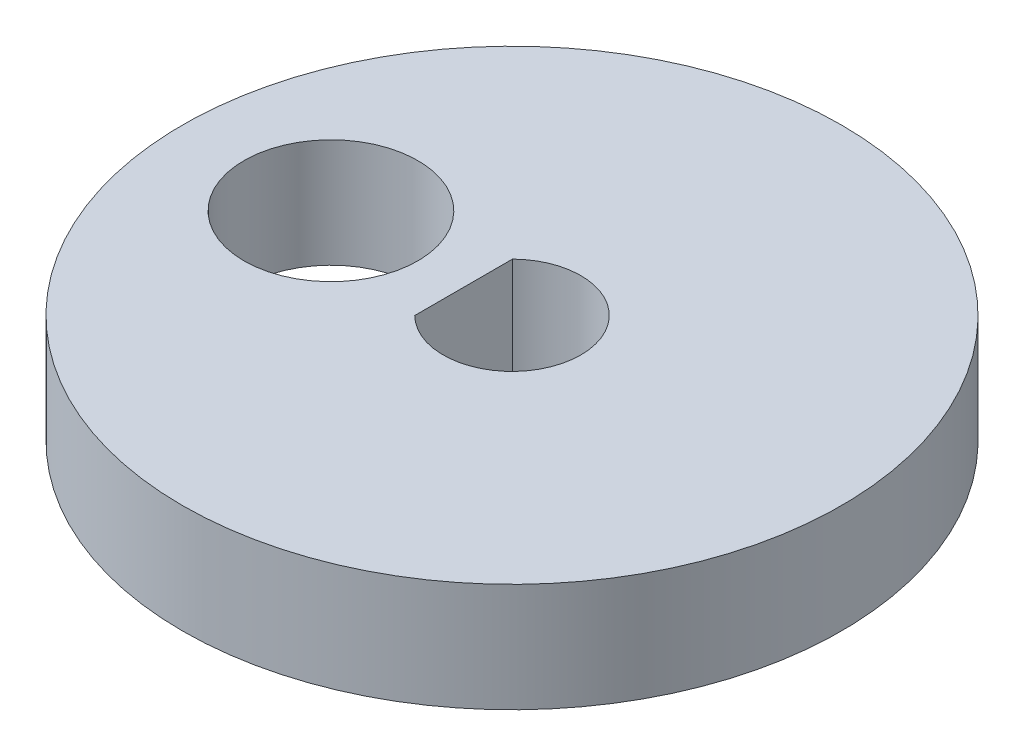
from build123d import *

# Parameters (mm, degrees)
SKETCH1_R           = 9.1
SKETCH1_R_2         = 2.4
BOSS_EXTRUDE1_DEPTH = 3


with BuildPart() as part:
    # Sketch1 → Boss-Extrude1 (new body)
    with BuildSketch(Plane(origin=(0, 0, 0), x_dir=(1, 0, 0), z_dir=(0, 1, 0))):
        Circle(SKETCH1_R)
        with Locations((-5, 0)):
            Circle(SKETCH1_R_2, mode=Mode.SUBTRACT)
        with BuildLine():
            Line((-1.336974196, 1.35), (-1.336974196, -1.35))
            ThreePointArc((-1.336974196, -1.35), (1.9, 0), (-1.336974196, 1.35))
        make_face(mode=Mode.SUBTRACT)
    extrude(amount=BOSS_EXTRUDE1_DEPTH)


solid = part.part
